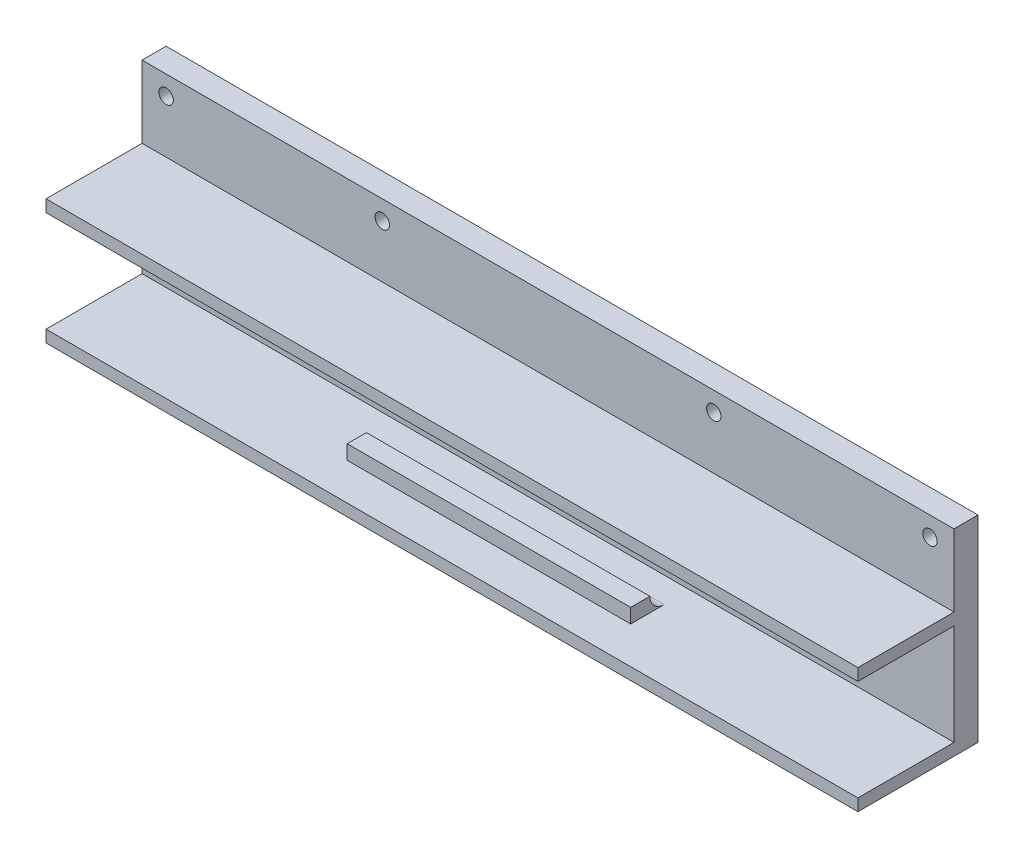
from build123d import *

# Parameters (mm, degrees)
SKETCH_1_W          = 169
SKETCH_1_H          = 41
EXTRUDE_2_DEPTH     = 5
SKETCH_3_R          = 1.5
CUT_EXTRUDE_1_DEPTH = 5
SKETCH_4_W          = 169
SKETCH_4_H          = 26
EXTRUDE_3_DEPTH     = 20
SKETCH_5_W          = 20
SKETCH_5_H          = 21
CUT_EXTRUDE_2_DEPTH = 55
SKETCH_6_W          = 20
SKETCH_6_H          = 21
CUT_EXTRUDE_3_DEPTH = 55
CUT_EXTRUDE_6_DEPTH = 59
SKETCH_10_W         = 7.7
SKETCH_10_H         = 21
CUT_EXTRUDE_7_DEPTH = 59
SKETCH_11_W         = 4
SKETCH_11_H         = 15
CUT_EXTRUDE_8_DEPTH = 59


with BuildPart() as part:
    # Эскиз1 → Бобышка-Вытянуть2 (new body)
    with BuildSketch(Plane.XY):
        Rectangle(SKETCH_1_W, SKETCH_1_H)
    extrude(amount=EXTRUDE_2_DEPTH)

    # Эскиз3 → Вырез-Вытянуть1 (cut)
    with BuildSketch(Plane.XY.offset(5)):
        with Locations((79.5, 16.5)):
            Circle(SKETCH_3_R)
        with Locations((34.5, 16.5)):
            Circle(SKETCH_3_R)
        with Locations((-34.5, 16.5)):
            Circle(SKETCH_3_R)
        with Locations((-79.5, 16.5)):
            Circle(SKETCH_3_R)
    extrude(amount=-CUT_EXTRUDE_1_DEPTH, mode=Mode.SUBTRACT)

    # Эскиз4 → Бобышка-Вытянуть3 (add)
    with BuildSketch(Plane.XY.offset(5)):
        with Locations((0, -7.5)):
            Rectangle(SKETCH_4_W, SKETCH_4_H)
    extrude(amount=EXTRUDE_3_DEPTH)

    # Эскиз5 → Вырез-Вытянуть2 (cut)
    with BuildSketch(Plane.ZY.offset(84.5)):
        with Locations((15, -7.5)):
            Rectangle(SKETCH_5_W, SKETCH_5_H)
    extrude(amount=-CUT_EXTRUDE_2_DEPTH, mode=Mode.SUBTRACT)

    # Эскиз6 → Вырез-Вытянуть3 (cut)
    with BuildSketch(Plane(origin=(84.5, 0, 0), x_dir=(0, 0, -1), z_dir=(1, 0, 0))):
        with Locations((-15, -7.5)):
            Rectangle(SKETCH_6_W, SKETCH_6_H)
    extrude(amount=-CUT_EXTRUDE_3_DEPTH, mode=Mode.SUBTRACT)

    # Эскиз7 → Вырез-Вытянуть6 (cut)
    with BuildSketch(Plane(origin=(29.5, 0, 0), x_dir=(0, 0, -1), z_dir=(1, 0, 0))):
        with BuildLine():
            Line((-5, 3), (-10.3, 3))
            ThreePointArc((-10.3, 3), (-12.421320344, 2.121320344), (-13.3, 0))
            Line((-13.3, 0), (-13.3, -15))
            ThreePointArc((-13.3, -15), (-12.421320344, -17.121320344), (-10.3, -18))
            Line((-10.3, -18), (-5, -18))
            Line((-5, -18), (-5, 3))
        make_face()
    extrude(amount=-CUT_EXTRUDE_6_DEPTH, mode=Mode.SUBTRACT)

    # Эскиз10 → Вырез-Вытянуть7 (cut)
    with BuildSketch(Plane(origin=(29.5, 0, 0), x_dir=(0, 0, -1), z_dir=(1, 0, 0))):
        with Locations((-21.15, -7.5)):
            Rectangle(SKETCH_10_W, SKETCH_10_H)
    extrude(amount=-CUT_EXTRUDE_7_DEPTH, mode=Mode.SUBTRACT)

    # Эскиз11 → Вырез-Вытянуть8 (cut)
    with BuildSketch(Plane(origin=(29.5, 0, 0), x_dir=(0, 0, -1), z_dir=(1, 0, 0))):
        with Locations((-15.3, -7.5)):
            Rectangle(SKETCH_11_W, SKETCH_11_H)
    extrude(amount=-CUT_EXTRUDE_8_DEPTH, mode=Mode.SUBTRACT)


solid = part.part
